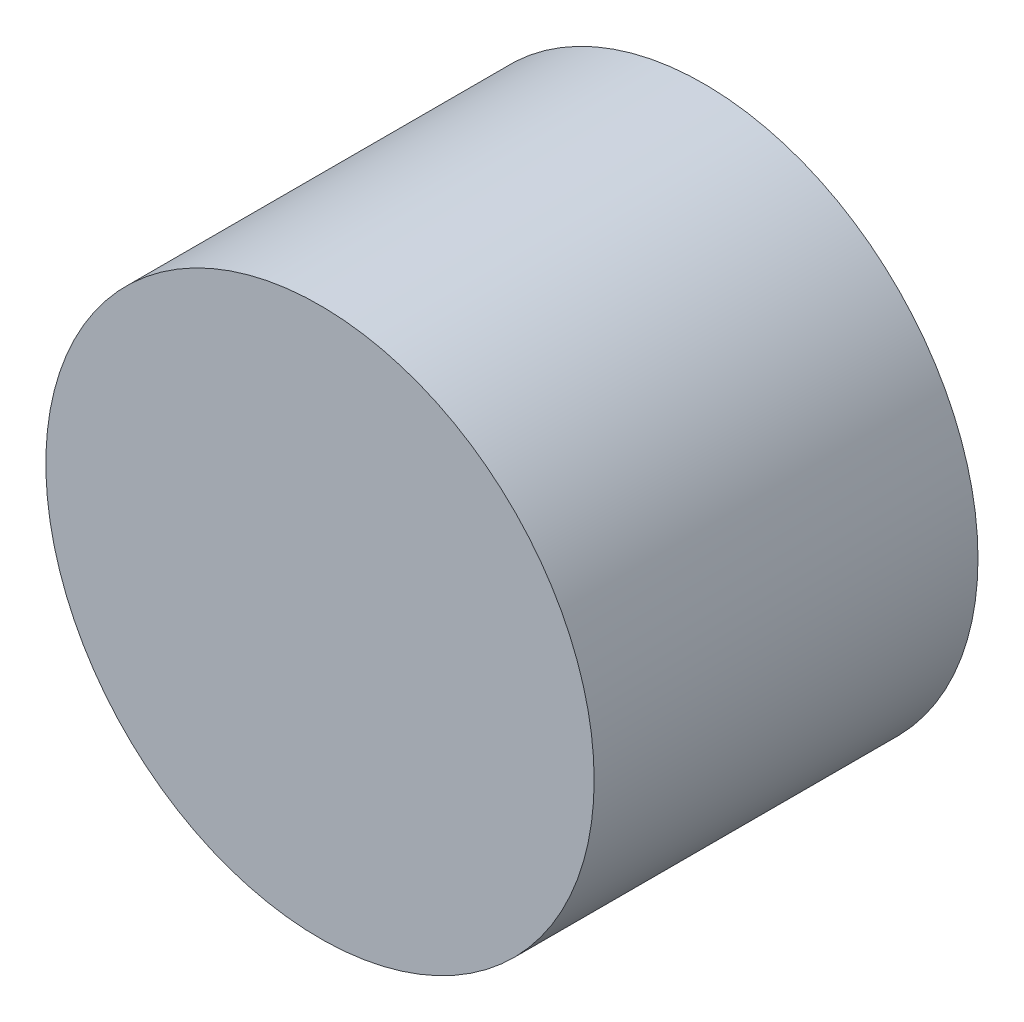
from build123d import *

# Parameters (mm, degrees)
SKETCH1_R           = 63.5
BOSS_EXTRUDE1_DEPTH = 44.45


with BuildPart() as part:
    # Sketch1 → Boss-Extrude1 (new body, symmetric)
    with BuildSketch(Plane.XY):
        Circle(SKETCH1_R)
    extrude(amount=BOSS_EXTRUDE1_DEPTH, both=True)


solid = part.part
